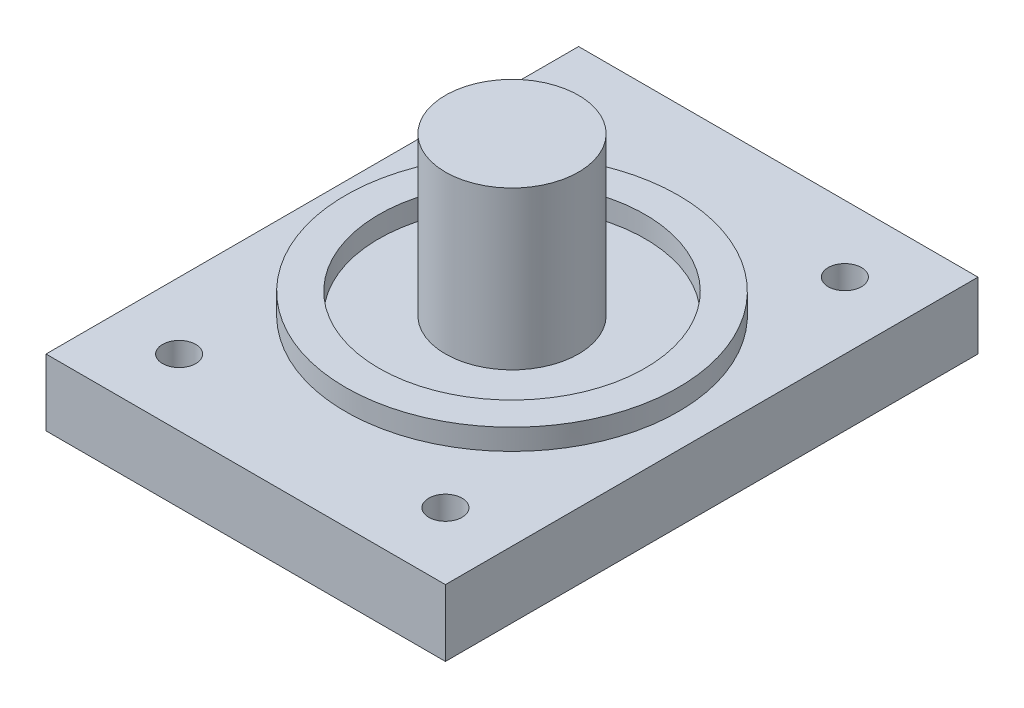
from build123d import *

# Parameters (mm, degrees)
SKETCH1_W           = 19.05
SKETCH1_H           = 25.4
BOSS_EXTRUDE1_DEPTH = 3.175
SKETCH2_R           = 3.175
BOSS_EXTRUDE2_DEPTH = 7.5125
SKETCH3_R           = 0.79375
CUT_EXTRUDE1_DEPTH  = 3.175
SKETCH4_R           = 7.9375
SKETCH4_R_2         = 6.35
BOSS_EXTRUDE3_DEPTH = 1


with BuildPart() as part:
    # Sketch1 → Boss-Extrude1 (new body)
    with BuildSketch(Plane(origin=(0, 0, 0), x_dir=(1, 0, 0), z_dir=(0, 1, 0))):
        with Locations((9.525, 12.7)):
            Rectangle(SKETCH1_W, SKETCH1_H)
    extrude(amount=BOSS_EXTRUDE1_DEPTH)

    # Sketch2 → Boss-Extrude2 (add)
    with BuildSketch(Plane(origin=(0, 3.175, 0), x_dir=(1, 0, 0), z_dir=(0, 1, 0))):
        with Locations((9.525, 12.7)):
            Circle(SKETCH2_R)
    extrude(amount=BOSS_EXTRUDE2_DEPTH)

    # Sketch3 → Cut-Extrude1 (cut)
    with BuildSketch(Plane(origin=(0, 3.175, 0), x_dir=(1, 0, 0), z_dir=(0, 1, 0))):
        with Locations((3.175, 22.225)):
            Circle(SKETCH3_R)
        with Locations((15.875, 22.225)):
            Circle(SKETCH3_R)
        with Locations((15.875, 3.175)):
            Circle(SKETCH3_R)
        with Locations((3.175, 3.175)):
            Circle(SKETCH3_R)
    extrude(amount=-CUT_EXTRUDE1_DEPTH, mode=Mode.SUBTRACT)

    # Sketch4 → Boss-Extrude3 (add)
    with BuildSketch(Plane(origin=(0, 3.175, 0), x_dir=(1, 0, 0), z_dir=(0, 1, 0))):
        with Locations((9.525, 12.7)):
            Circle(SKETCH4_R)
        with Locations((9.525, 12.7)):
            Circle(SKETCH4_R_2, mode=Mode.SUBTRACT)
    extrude(amount=BOSS_EXTRUDE3_DEPTH)


solid = part.part
